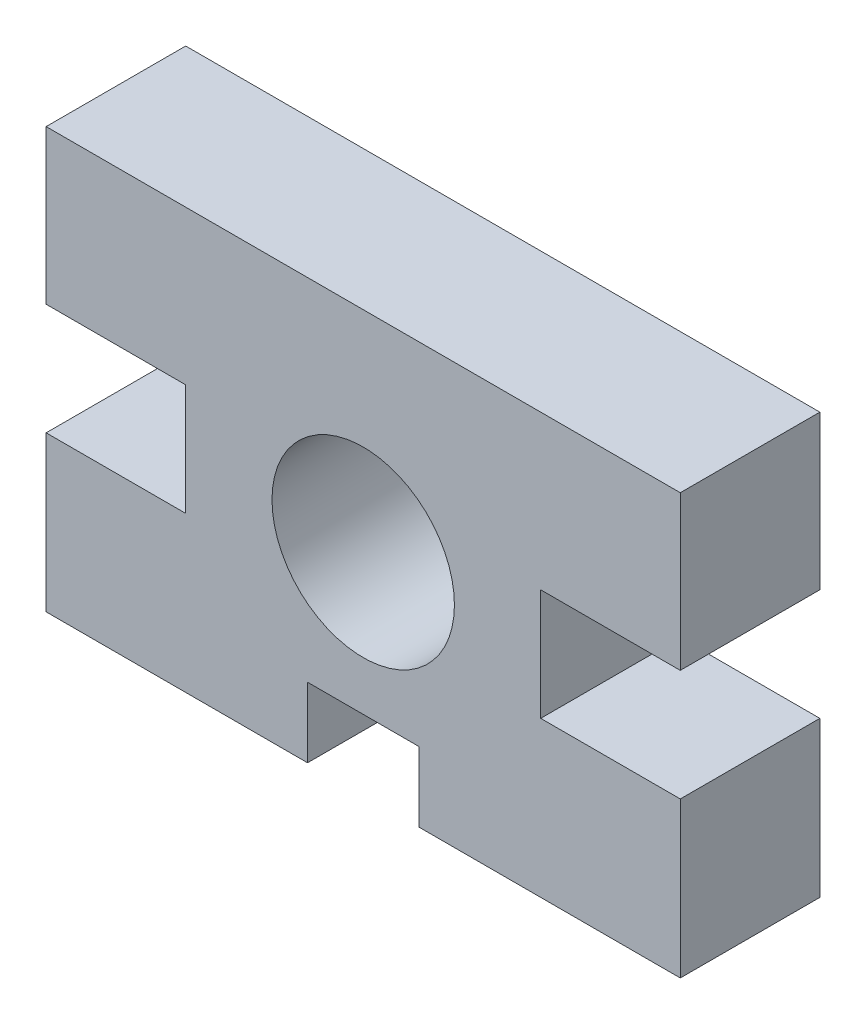
from build123d import *

# Parameters (mm, degrees)
SKETCH1_R           = 4.15
BOSS_EXTRUDE1_DEPTH = 6.35


with BuildPart() as part:
    # Sketch1 → Boss-Extrude1 (new body)
    with BuildSketch(Plane.XY):
        Polygon((-14.425, 9.56), (-14.425, 2.56), (-8.075, 2.56), (-8.075, -2.505147932), (-14.425, -2.505147932), (-14.425, -9.56), (-2.5325, -9.56), (-2.5325, -6.385), (0, -6.385), (2.5325, -6.385), (2.5325, -9.56), (14.425, -9.56), (14.425, -2.505147932), (8.075, -2.505147932), (8.075, 2.56), (14.425, 2.56), (14.425, 9.56), align=None)
        Circle(SKETCH1_R, mode=Mode.SUBTRACT)
    extrude(amount=BOSS_EXTRUDE1_DEPTH)


solid = part.part
